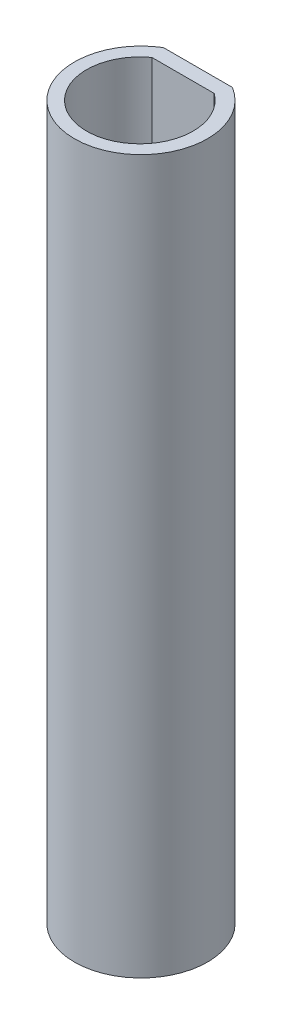
from build123d import *

# Parameters (mm, degrees)
BOSS_EXTRUDE1_DEPTH = 15
CUT_EXTRUDE1_DEPTH  = 16


with BuildPart() as part:
    # Sketch1 → Boss-Extrude1 (new body)
    with BuildSketch(Plane(origin=(0, 0, 0), x_dir=(1, 0, 0), z_dir=(0, 1, 0))):
        with BuildLine():
            Line((-0.725, 1.197653957), (0.725, 1.197653957))
            ThreePointArc((0.725, 1.197653957), (0, -1.4), (-0.725, 1.197653957))
        make_face()
    extrude(amount=BOSS_EXTRUDE1_DEPTH)

    # Sketch2 → Cut-Extrude1 (cut, through all)
    with BuildSketch(Plane.XZ):
        with BuildLine():
            Line((0.643996161, -0.896908605), (-0.666461143, -0.896908605))
            ThreePointArc((-0.666461143, -0.896908605), (-0.011232491, 1.133329018), (0.643996161, -0.896908605))
        make_face()
    extrude(amount=-CUT_EXTRUDE1_DEPTH, mode=Mode.SUBTRACT)


solid = part.part
